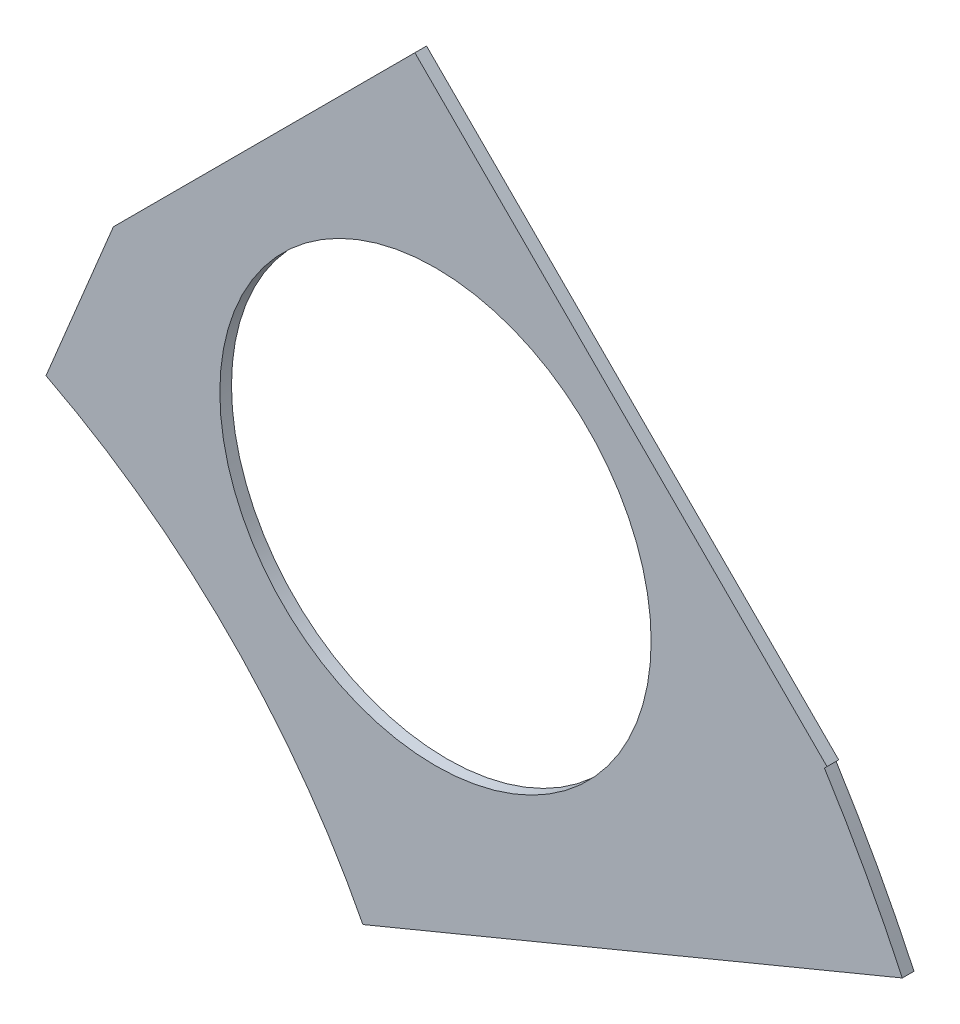
from build123d import *

# Parameters (mm, degrees)
BOSS_EXTRUDE1_DEPTH = 0.254
SKETCH2_R           = 4.699
CUT_EXTRUDE1_DEPTH  = 1.254
SKETCH3_W           = 2.54
SKETCH3_H           = 0.635
CUT_EXTRUDE2_DEPTH  = 1.254
SKETCH5_OUTSIDE_W   = 121.447
SKETCH5_OUTSIDE_H   = 109.618
CUT_EXTRUDE5_DEPTH  = 1.254


with BuildPart() as part:
    # Sketch1 → Boss-Extrude1 (new body)
    with BuildSketch(Plane.XY):
        with BuildLine():
            Line((67.21146711, 76.191723231), (8.696654013, 17.676910134))
            Line((8.696654013, 17.676910134), (7.228954972, 14.133571205))
            ThreePointArc((7.228954972, 14.133571205), (14.666587579, 6.075099489), (15.105587123, -4.88230096))
            Line((15.105587123, -4.88230096), (18.648926052, -6.35))
            Line((18.648926052, -6.35), (101.401368334, -6.35))
            ThreePointArc((101.401368334, -6.35), (93.866160503, 38.880636728), (67.21146711, 76.191723231))
        make_face()
        with BuildLine():
            Line((88.672924278, 6.35), (27.86051193, 6.35))
            ThreePointArc((27.86051193, 6.35), (26.399857642, 10.93517908), (24.190484974, 15.210228852))
            Line((24.190484974, 15.210228852), (67.191354125, 58.211098004))
            ThreePointArc((67.191354125, 58.211098004), (82.13289044, 34.020557137), (88.672924278, 6.35))
        make_face(mode=Mode.SUBTRACT)
    extrude(amount=BOSS_EXTRUDE1_DEPTH)

    # Sketch2 → Cut-Extrude1 (cut, through all)
    with BuildSketch(Plane.XY.offset(0.254)):
        with Locations((22.225, 0)):
            Circle(SKETCH2_R)
        with Locations((36.195, 0)):
            Circle(SKETCH2_R)
        with Locations((61.722, 0)):
            Circle(SKETCH2_R)
        with Locations((75.692, 0)):
            Circle(SKETCH2_R)
        with Locations((95.25, 0)):
            Circle(SKETCH2_R)
        with Locations((15.715448212, 15.715448212)):
            Circle(SKETCH2_R)
        with Locations((25.593729945, 25.593729945)):
            Circle(SKETCH2_R)
        with Locations((43.644044748, 43.644044748)):
            Circle(SKETCH2_R)
        with Locations((53.522326482, 53.522326482)):
            Circle(SKETCH2_R)
        with Locations((92.004434954, 24.652514046)):
            Circle(SKETCH2_R)
        with Locations((82.48891971, 47.625)):
            Circle(SKETCH2_R)
        with Locations((67.351920908, 67.351920908)):
            Circle(SKETCH2_R)
    extrude(amount=-CUT_EXTRUDE1_DEPTH, mode=Mode.SUBTRACT)

    # Sketch3 → Cut-Extrude2 (cut, through all)
    with BuildSketch(Plane.XY.offset(0.254)):
        Polygon((15.266435406, 24.246691527), (17.06248663, 26.042742751), (17.511499436, 25.593729945), (15.715448212, 23.797678721), align=None)
        Polygon((44.991083167, 53.971339288), (43.195031942, 52.175288063), (43.644044748, 51.726275257), (45.440095973, 53.522326482), align=None)
        with Locations((29.21, -6.0325)):
            Rectangle(SKETCH3_W, SKETCH3_H)
        with Locations((68.707, -6.0325)):
            Rectangle(SKETCH3_W, SKETCH3_H)
        Polygon((29.230733674, 38.210989795), (31.026784898, 40.007041019), (31.475797704, 39.558028213), (29.67974648, 37.761976989), align=None)
        Polygon((56.845021246, 65.825277367), (55.048970022, 64.029226143), (55.497982828, 63.580213337), (57.294034052, 65.376264561), align=None)
        with Locations((48.9585, -6.0325)):
            Rectangle(SKETCH3_W, SKETCH3_H)
        with Locations((85.471, -6.0325)):
            Rectangle(SKETCH3_W, SKETCH3_H)
        Polygon((99.935462164, 14.437711971), (100.266998693, 11.919442024), (101.526133667, 12.085210288), (101.194597138, 14.603480236), align=None)
        Polygon((93.765504959, 37.464305742), (94.938831965, 37.950313702), (93.966816047, 40.296967714), (92.793489041, 39.810959755), align=None)
        Polygon((79.327792988, 62.471156422), (80.874047017, 60.456038938), (81.88160576, 61.229165953), (80.33535173, 63.244283437), align=None)
        Polygon((13.593916116, 7.005422516), (14.565932035, 4.658768503), (15.739259041, 5.144776462), (14.767243123, 7.491430475), align=None)
    extrude(amount=-CUT_EXTRUDE2_DEPTH, mode=Mode.SUBTRACT)

    # Sketch5 outside → Cut-Extrude5 (cut, through all)
    with BuildSketch(Plane.XY.offset(0.254)):
        with Locations((54.4145, 34.921)):
            Rectangle(SKETCH5_OUTSIDE_W, SKETCH5_OUTSIDE_H)
        Polygon((8.194751981, 4.769015505), (26.967984082, 12.545142851), (12.599574288, 26.913552645), (-0.675105435, 13.638872921), align=None, mode=Mode.SUBTRACT)
    extrude(amount=-CUT_EXTRUDE5_DEPTH, mode=Mode.SUBTRACT)


solid = part.part
